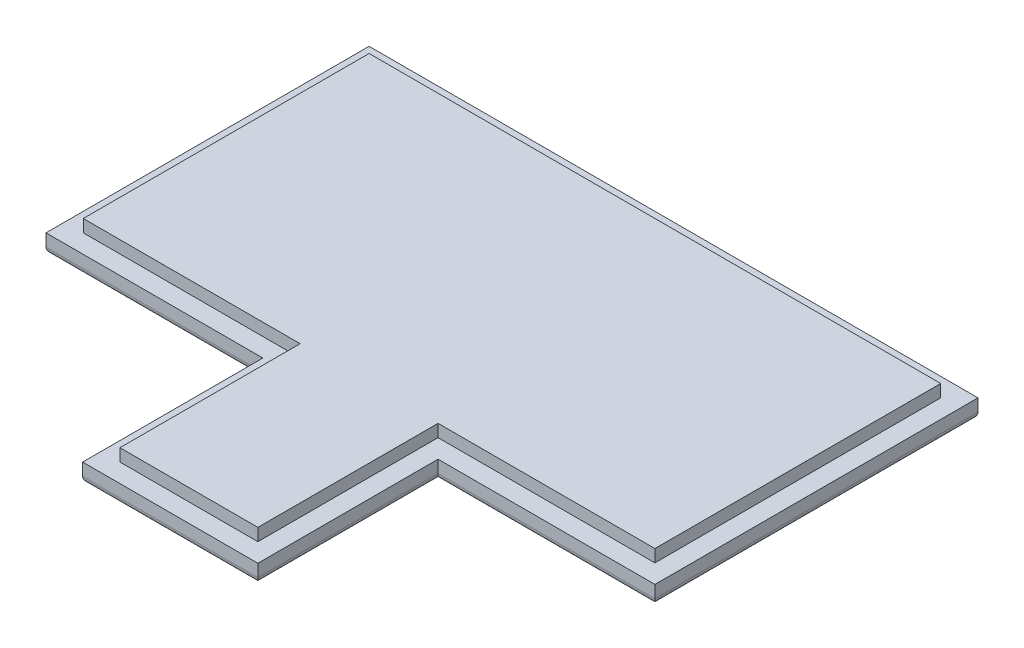
from build123d import *

# Parameters (mm, degrees)
EXTRUDE_1_DEPTH = 1.5
EXTRUDE_2_DEPTH = 1
FILLET_1_R      = 0.5


with BuildPart() as part:
    # 草图1 → 凸台-拉伸1 (new body)
    with BuildSketch(Plane(origin=(0, 0, 0), x_dir=(1, 0, 0), z_dir=(0, 1, 0))):
        Polygon((-24.5, 13), (24.5, 13), (24.5, -13), (7.05, -13), (7.05, -26), (7.05, -27.5), (-7.05, -27.5), (-7.05, -26), (-7.05, -13), (-24.5, -13), align=None)
    extrude(amount=EXTRUDE_1_DEPTH)

    # 草图2 → 凸台-拉伸2 (add)
    with BuildSketch(Plane(origin=(0, 1.5, 0), x_dir=(1, 0, 0), z_dir=(0, 1, 0))):
        Polygon((23, 11.5), (23, -11.5), (5.55, -11.5), (5.55, -13), (5.55, -24.5), (5.55, -26), (-5.55, -26), (-5.55, -24.5), (-5.55, -13), (-5.55, -11.5), (-23, -11.5), (-23, 11.5), align=None)
    extrude(amount=EXTRUDE_2_DEPTH)

    # 圆角1
    fillet_1_edges = [part.edges().sort_by_distance(p)[0] for p in [
        (7.05, 0, 20.25),
        (0, 0, 27.5),
        (-7.05, 0, 20.25),
        (-15.775, 0, 13),
        (-24.5, 0, 0),
        (0, 0, -13),
        (24.5, 0, 0),
        (15.775, 0, 13),
    ]]
    fillet(fillet_1_edges, radius=FILLET_1_R)


solid = part.part
